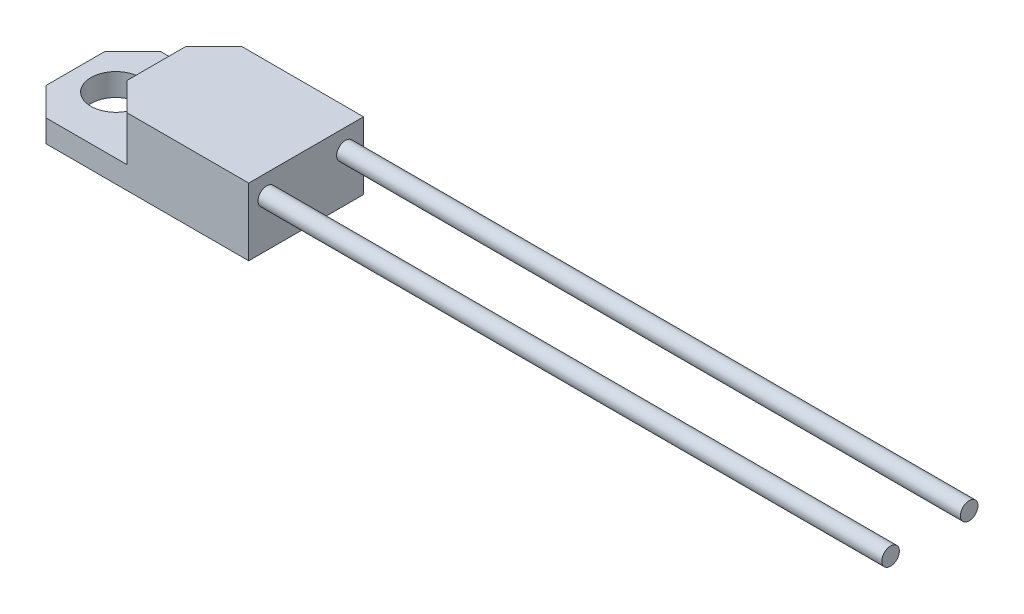
from build123d import *

# Parameters (mm, degrees)
SKETCH1_W           = 18.5
SKETCH1_H           = 9.2
BOSS_EXTRUDE1_DEPTH = 1.8
SKETCH3_W           = 12
SKETCH3_H           = 9.2
BOSS_EXTRUDE3_DEPTH = 3.6
SKETCH2_R           = 0.705
BOSS_EXTRUDE2_DEPTH = 50
SKETCH4_R           = 2
CUT_EXTRUDE1_DEPTH  = 2.8
CHAMFER1_SIZE       = 2.25


with BuildPart() as part:
    # Sketch1 → Boss-Extrude1 (new body)
    with BuildSketch(Plane(origin=(0, 0, 0), x_dir=(1, 0, 0), z_dir=(0, 1, 0))):
        Rectangle(SKETCH1_W, SKETCH1_H)
    extrude(amount=BOSS_EXTRUDE1_DEPTH)

    # Sketch3 → Boss-Extrude3 (add)
    with BuildSketch(Plane(origin=(0, 1.8, 0), x_dir=(1, 0, 0), z_dir=(0, 1, 0))):
        with Locations((3.25, 0)):
            Rectangle(SKETCH3_W, SKETCH3_H)
    extrude(amount=BOSS_EXTRUDE3_DEPTH)

    # Sketch2 → Boss-Extrude2 (add)
    with BuildSketch(Plane(origin=(9.25, 0, 0), x_dir=(0, 0, -1), z_dir=(1, 0, 0))):
        with Locations((-3.15, 3.78)):
            Circle(SKETCH2_R)
        with Locations((3.15, 3.78)):
            Circle(SKETCH2_R)
    extrude(amount=BOSS_EXTRUDE2_DEPTH)

    # Sketch4 → Cut-Extrude1 (cut, through all)
    with BuildSketch(Plane(origin=(0, 1.8, 0), x_dir=(1, 0, 0), z_dir=(0, 1, 0))):
        with Locations((-6, 0)):
            Circle(SKETCH4_R)
    extrude(amount=-CUT_EXTRUDE1_DEPTH, mode=Mode.SUBTRACT)

    # Chamfer1
    chamfer1_edges = [part.edges().sort_by_distance(p)[0] for p in [
        (-9.25, 0.9, -4.6),
        (-9.25, 0.9, 4.6),
        (-2.75, 3.6, -4.6),
        (-2.75, 3.6, 4.6),
    ]]
    chamfer(chamfer1_edges, length=CHAMFER1_SIZE)


solid = part.part
